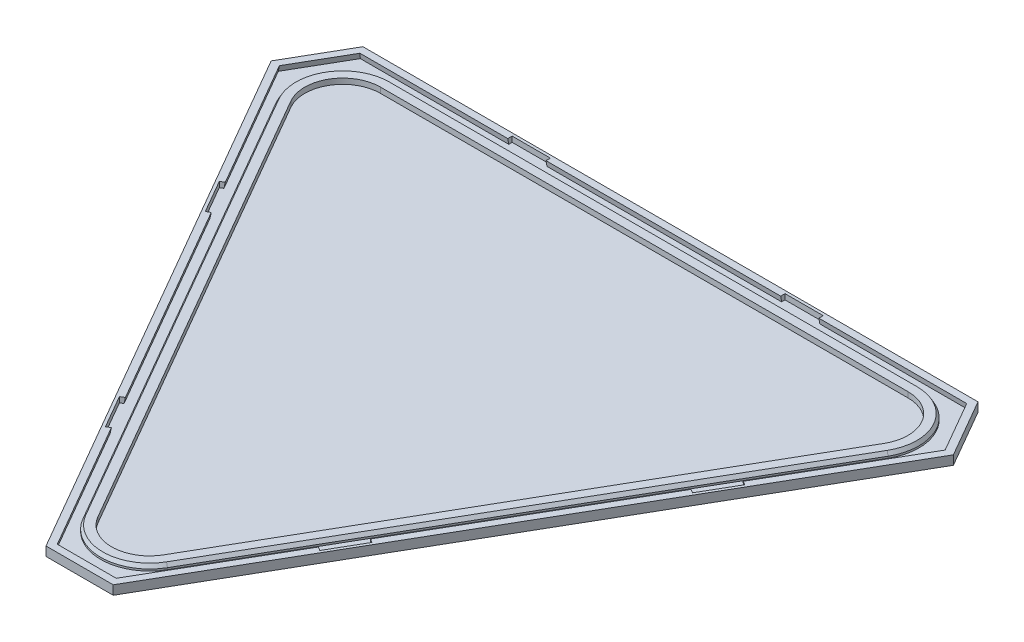
from build123d import *
from OCP.BRepFilletAPI import BRepFilletAPI_MakeChamfer

# Parameters (mm, degrees)
SMARTLEAF_TRIANGLE_MULTI_DEPTH  = 1
EXTRU_MINCE1_DEPTH              = 1.5
EXTRU_MINCE1_DRAFT              = -10
ENL_V_DE_MAT_EXTRU_MINCE1_DEPTH = 140.660166399
ESQUISSE10_W                    = 10.5
ESQUISSE10_H                    = 19.000079823
ENL_V_MAT_EXTRU_1_DEPTH         = 1.5
EXTRU_MINCE2_DEPTH              = 1.5
CHANFREIN1_SIZE                 = 1
CHANFREIN1_SIZE2                = 0.577350269


with BuildPart() as part:
    # Esquisse2 → smartleaf_triangle_multi (new body)
    with BuildSketch(Plane(origin=(0, 0, 0), x_dir=(1, 0, 0), z_dir=(0, 1, 0))):
        Polygon((-93.762395693, 43.467077727), (-84.524791386, 59.467077727), (84.524791386, 59.467077727), (93.762395693, 43.467077727), (9.237604307, -102.934155453), (-9.237604307, -102.934155453), align=None)
    extrude(amount=SMARTLEAF_TRIANGLE_MULTI_DEPTH)


with BuildPart() as extru_mince1_tool:
    # Esquisse5 → Extru.-Mince1 (with draft: the straight prism first)
    with BuildSketch(Plane(origin=(0, 1, 0), x_dir=(1, 0, 0), z_dir=(0, 1, 0))):
        Polygon((-93.762395693, 43.467077727), (-9.237604307, -102.934155453), (9.237604307, -102.934155453), (93.762395693, 43.467077727), (84.524791386, 59.467077727), (-84.524791386, 59.467077727), align=None)
        Polygon((-91.799404778, 43.467077727), (-8.256108849, -101.234155453), (8.256108849, -101.234155453), (91.799404778, 43.467077727), (83.543295928, 57.767077727), (-83.543295928, 57.767077727), align=None, mode=Mode.SUBTRACT)
    extrude(amount=EXTRU_MINCE1_DEPTH)
    # Extru.-Mince1: the draft: its side faces are tilted about the plane it starts from
    extru_mince1_sides = [extru_mince1_tool.faces().sort_by_distance(p)[0] for p in [
        (-51.5, 1.75, 29.733538863),
        (0, 1.75, 102.934155453),
        (51.5, 1.75, 29.733538863),
        (89.143593539, 1.75, -51.467077727),
        (0, 1.75, -59.467077727),
        (-89.143593539, 1.75, -51.467077727),
        (-87.671350353, 1.75, -50.617077727),
        (0, 1.75, -57.767077727),
        (87.671350353, 1.75, -50.617077727),
        (50.027756814, 1.75, 28.883538863),
        (0, 1.75, 101.234155453),
        (-50.027756814, 1.75, 28.883538863),
    ]]
    draft(extru_mince1_sides, Plane(origin=(0, 1, 0), x_dir=(1, 0, 0), z_dir=(0, 1, 0)), EXTRU_MINCE1_DRAFT)


with BuildPart() as part_1:
    add(part.part)

    # Extru.-Mince1: add extru_mince1_tool
    add(extru_mince1_tool.part)

    # Esquisse6 → Enlèv. de mat.-Extru.-Mince1 (cut, through all)
    with BuildSketch(Plane.XZ):
        Polygon((-85.39081679, -60.967077727), (85.39081679, -60.967077727), (95.494446501, -43.467077727), (10.103629711, 104.434155453), (-10.103629711, 104.434155453), (-95.494446501, -43.467077727), align=None)
        Polygon((-84.524791386, -59.467077727), (84.524791386, -59.467077727), (93.762395693, -43.467077727), (9.237604307, 102.934155453), (-9.237604307, 102.934155453), (-93.762395693, -43.467077727), align=None, mode=Mode.SUBTRACT)
    extrude(amount=-ENL_V_DE_MAT_EXTRU_MINCE1_DEPTH, mode=Mode.SUBTRACT)

    # Esquisse10 → Enlèv. mat.-Extru.1 (cut)
    with BuildSketch(Plane(origin=(0, 2.5, 0), x_dir=(1, 0, 0), z_dir=(0, 1, 0))):
        with Locations((-37.5, 49.202547344)):
            Rectangle(ESQUISSE10_W, ESQUISSE10_H)
        with Locations((37.5, 49.202547344)):
            Rectangle(ESQUISSE10_W, ESQUISSE10_H)
        Polygon((66.962931831, -1.421974356), (72.212931831, 7.671292384), (55.75838003, 17.171332296), (50.50838003, 8.078065556), align=None)
        Polygon((29.462931831, -66.37387964), (13.00838003, -56.873839728), (18.25838003, -47.780572988), (34.712931831, -57.2806129), align=None)
        Polygon((-34.712931831, -57.2806129), (-29.462931831, -66.37387964), (-13.00838003, -56.873839728), (-18.25838003, -47.780572988), align=None)
        Polygon((-72.212931831, 7.671292384), (-55.75838003, 17.171332296), (-50.50838003, 8.078065556), (-66.962931831, -1.421974356), align=None)
    extrude(amount=-ENL_V_MAT_EXTRU_1_DEPTH, mode=Mode.SUBTRACT)


with BuildPart() as body_2:
    # Esquisse11 → Extru.-Mince2 (new body)
    with BuildSketch(Plane(origin=(0, 1, 0), x_dir=(1, 0, 0), z_dir=(0, 1, 0))):
        with BuildLine():
            Line((-84.112693304, 35.153302911), (-11.612693304, -90.420380638))
            ThreePointArc((-11.612693304, -90.420380638), (0, -97.124972243), (11.612693304, -90.420380638))
            Line((11.612693304, -90.420380638), (84.112693304, 35.153302911))
            ThreePointArc((84.112693304, 35.153302911), (84.112693304, 48.562486121), (72.5, 55.267077727))
            Line((72.5, 55.267077727), (-72.5, 55.267077727))
            ThreePointArc((-72.5, 55.267077727), (-84.112693304, 48.562486121), (-84.112693304, 35.153302911))
        make_face()
        with BuildLine():
            Line((-81.514617093, 36.653302911), (-9.014617093, -88.920380638))
            ThreePointArc((-9.014617093, -88.920380638), (0, -94.124972243), (9.014617093, -88.920380638))
            Line((9.014617093, -88.920380638), (81.514617093, 36.653302911))
            ThreePointArc((81.514617093, 36.653302911), (81.514617093, 47.062486121), (72.5, 52.267077727))
            Line((72.5, 52.267077727), (-72.5, 52.267077727))
            ThreePointArc((-72.5, 52.267077727), (-81.514617093, 47.062486121), (-81.514617093, 36.653302911))
        make_face(mode=Mode.SUBTRACT)
    extrude(amount=EXTRU_MINCE2_DEPTH)

    # Chanfrein1: one chamfer whose edges measure the first distance from different faces: ONE call of the kernel's chamfer builder (chamfer() names one face for all edges)
    chanfrein1_edges_1 = [body_2.edges().sort_by_distance(p)[0] for p in [
        (47.862693304, 2.5, 27.633538863),
    ]]
    chanfrein1_side_1 = [body_2.faces().sort_by_distance(p)[0] for p in [
        (47.862693304, 1.75, 27.633538863),
    ]]
    chanfrein1_edges_2 = [body_2.edges().sort_by_distance(p)[0] for p in [
        (84.112693304, 2.5, -48.562486121),
    ]]
    chanfrein1_side_2 = [body_2.faces().sort_by_distance(p)[0] for p in [
        (84.112693304, 1.75, -48.562486121),
    ]]
    chanfrein1_edges_3 = [body_2.edges().sort_by_distance(p)[0] for p in [
        (0, 2.5, -55.267077727),
    ]]
    chanfrein1_side_3 = [body_2.faces().sort_by_distance(p)[0] for p in [
        (0, 1.75, -55.267077727),
    ]]
    chanfrein1_edges_4 = [body_2.edges().sort_by_distance(p)[0] for p in [
        (-84.112693304, 2.5, -48.562486121),
    ]]
    chanfrein1_side_4 = [body_2.faces().sort_by_distance(p)[0] for p in [
        (-84.112693304, 1.75, -48.562486121),
    ]]
    chanfrein1_edges_5 = [body_2.edges().sort_by_distance(p)[0] for p in [
        (-47.862693304, 2.5, 27.633538863),
    ]]
    chanfrein1_side_5 = [body_2.faces().sort_by_distance(p)[0] for p in [
        (-47.862693304, 1.75, 27.633538863),
    ]]
    chanfrein1_edges_6 = [body_2.edges().sort_by_distance(p)[0] for p in [
        (0, 2.5, 97.124972243),
    ]]
    chanfrein1_side_6 = [body_2.faces().sort_by_distance(p)[0] for p in [
        (0, 1.75, 97.124972243),
    ]]
    chanfrein1 = BRepFilletAPI_MakeChamfer(body_2.part.solid().wrapped)
    for e in chanfrein1_edges_1:
        chanfrein1.Add(CHANFREIN1_SIZE, CHANFREIN1_SIZE2, e.wrapped, chanfrein1_side_1[0].wrapped)  # the first distance lies on this face
    for e in chanfrein1_edges_2:
        chanfrein1.Add(CHANFREIN1_SIZE, CHANFREIN1_SIZE2, e.wrapped, chanfrein1_side_2[0].wrapped)  # the first distance lies on this face
    for e in chanfrein1_edges_3:
        chanfrein1.Add(CHANFREIN1_SIZE, CHANFREIN1_SIZE2, e.wrapped, chanfrein1_side_3[0].wrapped)  # the first distance lies on this face
    for e in chanfrein1_edges_4:
        chanfrein1.Add(CHANFREIN1_SIZE, CHANFREIN1_SIZE2, e.wrapped, chanfrein1_side_4[0].wrapped)  # the first distance lies on this face
    for e in chanfrein1_edges_5:
        chanfrein1.Add(CHANFREIN1_SIZE, CHANFREIN1_SIZE2, e.wrapped, chanfrein1_side_5[0].wrapped)  # the first distance lies on this face
    for e in chanfrein1_edges_6:
        chanfrein1.Add(CHANFREIN1_SIZE, CHANFREIN1_SIZE2, e.wrapped, chanfrein1_side_6[0].wrapped)  # the first distance lies on this face
    add(Compound.cast(chanfrein1.Shape()), mode=Mode.REPLACE)


solid = Compound([part_1.part, body_2.part])
